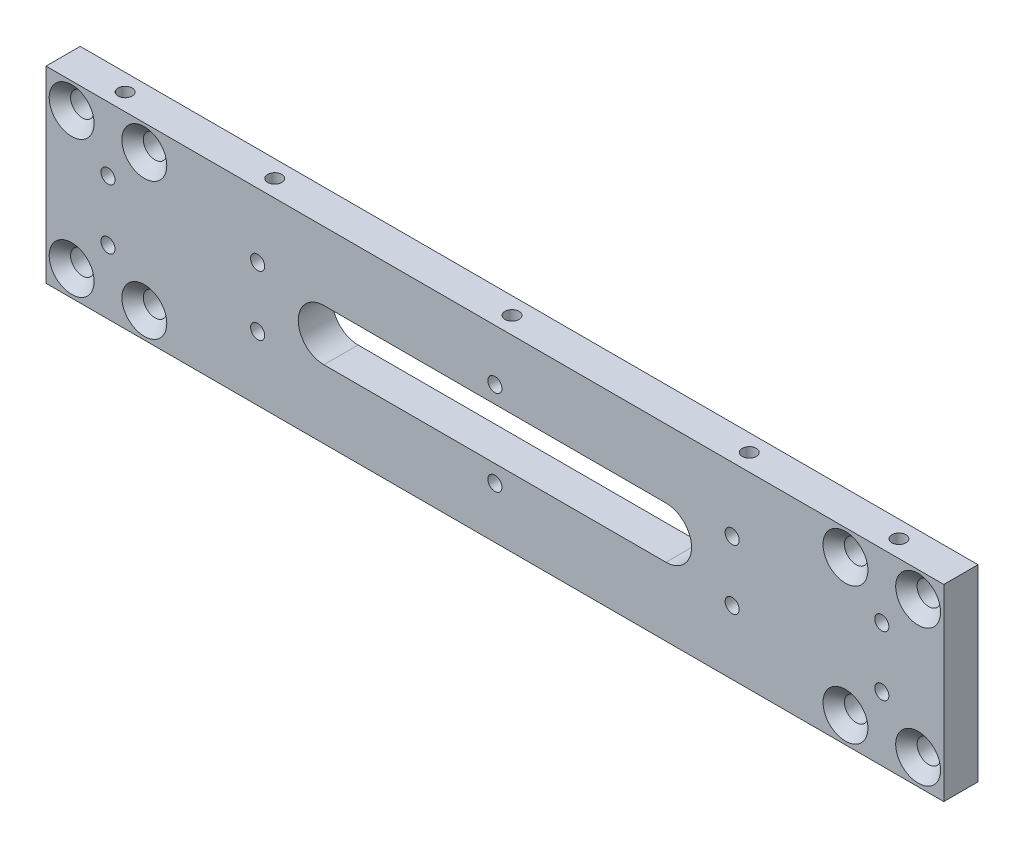
from build123d import *

# Parameters (mm, degrees)
ESQUISSE1_W             = 210
ESQUISSE1_H             = 44
BOSS_EXTRU_1_DEPTH      = 8
ESQUISSE2_R             = 2.75
ENL_V_MAT_EXTRU_1_DEPTH = 9
CHANFREIN1_SIZE         = 2.5
ENL_V_MAT_EXTRU_2_DEPTH = 9
ESQUISSE4_R             = 1.65
ENL_V_MAT_EXTRU_3_DEPTH = 9
ESQUISSE5_R             = 1.65
ENL_V_MAT_EXTRU_4_DEPTH = 8
ESQUISSE6_R             = 1.65
ENL_V_MAT_EXTRU_5_DEPTH = 8


with BuildPart() as part:
    # Esquisse1 → Boss.-Extru.1 (new body)
    with BuildSketch(Plane.XY):
        with Locations((31.855664279, -10.840611814)):
            Rectangle(ESQUISSE1_W, ESQUISSE1_H)
    extrude(amount=BOSS_EXTRU_1_DEPTH)

    # Esquisse2 → Enlèv. mat.-Extru.1 (cut, through all)
    with BuildSketch(Plane.XY.offset(8)):
        with Locations((-67.144335721, 5.159388186)):
            Circle(ESQUISSE2_R)
        with Locations((-67.144335721, -26.840611814)):
            Circle(ESQUISSE2_R)
        with Locations((-50.144335721, 5.159388186)):
            Circle(ESQUISSE2_R)
        with Locations((-50.144335721, -26.840611814)):
            Circle(ESQUISSE2_R)
        with Locations((130.855664279, 5.159388186)):
            Circle(ESQUISSE2_R)
        with Locations((130.855664279, -26.840611814)):
            Circle(ESQUISSE2_R)
        with Locations((113.855664279, 5.159388186)):
            Circle(ESQUISSE2_R)
        with Locations((113.855664279, -26.840611814)):
            Circle(ESQUISSE2_R)
    extrude(amount=-ENL_V_MAT_EXTRU_1_DEPTH, mode=Mode.SUBTRACT)

    # Chanfrein1
    chanfrein1_edges = [part.edges().sort_by_distance(p)[0] for p in [
        (-69.894335721, 5.159388186, 8),
        (-69.894335721, -26.840611814, 8),
        (-52.894335721, 5.159388186, 8),
        (-52.894335721, -26.840611814, 8),
        (128.105664279, 5.159388186, 8),
        (128.105664279, -26.840611814, 8),
        (111.105664279, 5.159388186, 8),
        (111.105664279, -26.840611814, 8),
    ]]
    chamfer(chanfrein1_edges, length=CHANFREIN1_SIZE)

    # Esquisse3 → Enlèv. mat.-Extru.2 (cut, through all)
    with BuildSketch(Plane.XY.offset(8)):
        with BuildLine():
            Line((-8.144335721, -4.840611814), (71.855664279, -4.840611814))
            ThreePointArc((71.855664279, -4.840611814), (77.855664279, -10.840611814), (71.855664279, -16.840611814))
            Line((71.855664279, -16.840611814), (-8.144335721, -16.840611814))
            ThreePointArc((-8.144335721, -16.840611814), (-14.144335721, -10.840611814), (-8.144335721, -4.840611814))
        make_face()
    extrude(amount=-ENL_V_MAT_EXTRU_2_DEPTH, mode=Mode.SUBTRACT)

    # Esquisse4 → Enlèv. mat.-Extru.3 (cut, through all)
    with BuildSketch(Plane.XY.offset(8)):
        with Locations((-58.644335721, -17.840611814)):
            Circle(ESQUISSE4_R)
        with Locations((-58.644335721, -3.840611814)):
            Circle(ESQUISSE4_R)
        with Locations((-23.644335721, -3.840611814)):
            Circle(ESQUISSE4_R)
        with Locations((-23.644335721, -17.840611814)):
            Circle(ESQUISSE4_R)
        with Locations((87.355664279, -3.840611814)):
            Circle(ESQUISSE4_R)
        with Locations((87.355664279, -17.840611814)):
            Circle(ESQUISSE4_R)
        with Locations((122.355664279, -3.840611814)):
            Circle(ESQUISSE4_R)
        with Locations((122.355664279, -17.840611814)):
            Circle(ESQUISSE4_R)
        with Locations((31.855664279, -0.840611814)):
            Circle(ESQUISSE4_R)
        with Locations((31.855664279, -20.840611814)):
            Circle(ESQUISSE4_R)
    extrude(amount=-ENL_V_MAT_EXTRU_3_DEPTH, mode=Mode.SUBTRACT)

    # Esquisse5 → Enlèv. mat.-Extru.4 (cut)
    with BuildSketch(Plane(origin=(0, 11.159388186, 0), x_dir=(1, 0, 0), z_dir=(0, 1, 0))):
        with Locations(Location((-58.644335721, -4, 0), (0, 0, 270))):  # turned: the seam where the file's is
            Circle(ESQUISSE5_R)
        with Locations(Location((-23.644335721, -4, 0), (0, 0, 270))):  # turned: the seam where the file's is
            Circle(ESQUISSE5_R)
        with Locations(Location((87.355664279, -4, 0), (0, 0, 270))):  # turned: the seam where the file's is
            Circle(ESQUISSE5_R)
        with Locations(Location((122.355664279, -4, 0), (0, 0, 270))):  # turned: the seam where the file's is
            Circle(ESQUISSE5_R)
        with Locations(Location((31.855664279, -4, 0), (0, 0, 270))):  # turned: the seam where the file's is
            Circle(ESQUISSE5_R)
    extrude(amount=-ENL_V_MAT_EXTRU_4_DEPTH, mode=Mode.SUBTRACT)

    # Esquisse6 → Enlèv. mat.-Extru.5 (cut)
    with BuildSketch(Plane.XZ.offset(32.840611814)):
        with Locations(Location((-58.644335721, 4, 0), (0, 0, 90))):  # turned: the seam where the file's is
            Circle(ESQUISSE6_R)
        with Locations(Location((-23.644335721, 4, 0), (0, 0, 90))):  # turned: the seam where the file's is
            Circle(ESQUISSE6_R)
        with Locations(Location((87.355664279, 4, 0), (0, 0, 90))):  # turned: the seam where the file's is
            Circle(ESQUISSE6_R)
        with Locations(Location((122.355664279, 4, 0), (0, 0, 90))):  # turned: the seam where the file's is
            Circle(ESQUISSE6_R)
        with Locations(Location((31.855664279, 4, 0), (0, 0, 90))):  # turned: the seam where the file's is
            Circle(ESQUISSE6_R)
    extrude(amount=-ENL_V_MAT_EXTRU_5_DEPTH, mode=Mode.SUBTRACT)


solid = part.part
